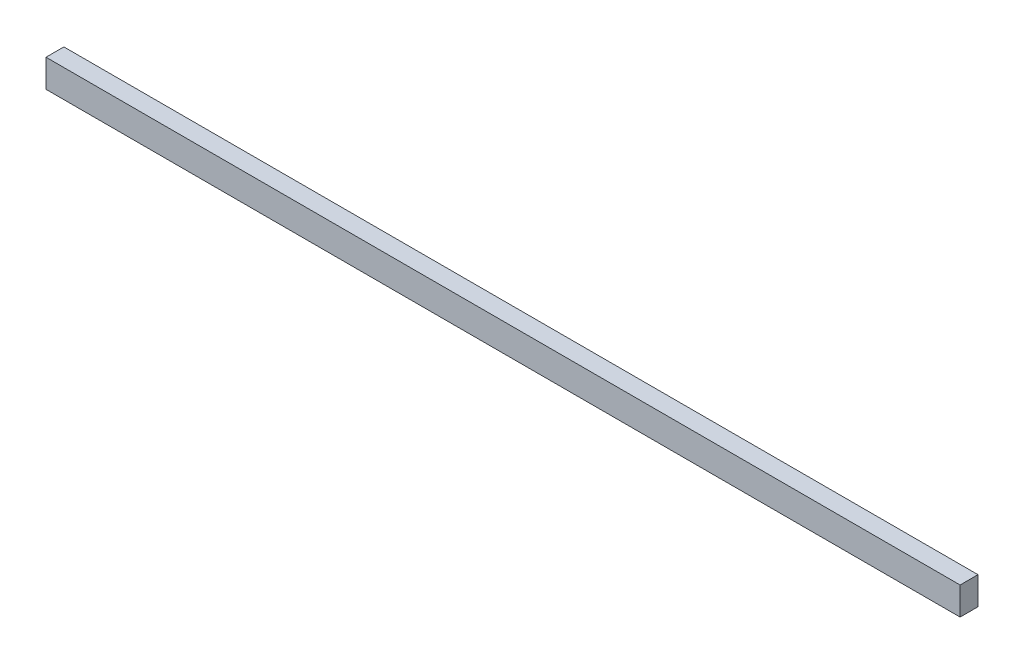
from build123d import *

# Parameters (mm, degrees)
SKETCH1_W           = 45
SKETCH1_H           = 70
BOSS_EXTRUDE1_DEPTH = 2300


with BuildPart() as part:
    # Sketch1 → Boss-Extrude1 (new body)
    with BuildSketch(Plane(origin=(0, 0, 0), x_dir=(0, 0, -1), z_dir=(1, 0, 0))):
        with Locations((22.5, -35)):
            Rectangle(SKETCH1_W, SKETCH1_H)
    extrude(amount=BOSS_EXTRUDE1_DEPTH)


solid = part.part
